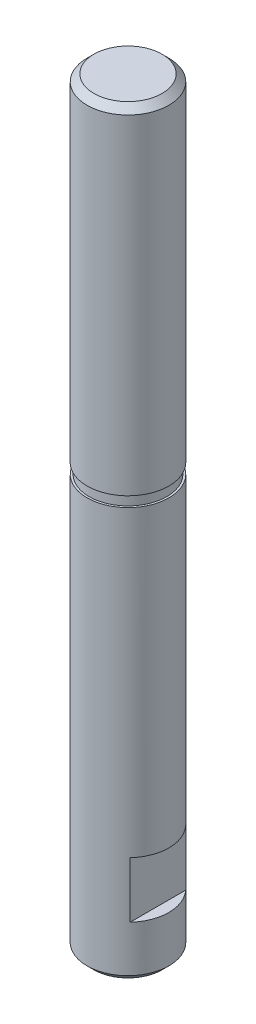
from build123d import *

# Parameters (mm, degrees)
SKETCH1_R           = 3
BOSS_EXTRUDE1_DEPTH = 55.7
SKETCH2_W           = 0.8
SKETCH2_H           = 4.1
CUT_EXTRUDE1_DEPTH  = 4
SKETCH3_W           = 0.15
SKETCH3_H           = 0.75
CHAMFER1_SIZE       = 0.5


with BuildPart() as part:
    # Sketch1 → Boss-Extrude1 (new body)
    with BuildSketch(Plane(origin=(0, 0, 0), x_dir=(1, 0, 0), z_dir=(0, 1, 0))):
        Circle(SKETCH1_R)
    extrude(amount=BOSS_EXTRUDE1_DEPTH)

    # Sketch2 → Cut-Extrude1 (cut, symmetric)
    with BuildSketch(Plane.XY):
        with Locations((-2.6, 5.95)):
            Rectangle(SKETCH2_W, SKETCH2_H)
    cut_extrude1 = extrude(amount=CUT_EXTRUDE1_DEPTH, both=True, mode=Mode.SUBTRACT)

    # Mirror1: Cut-Extrude1 across plane
    add(cut_extrude1.mirror(Plane(origin=(0, 0, 0), x_dir=(0, 0, 1), z_dir=(1, 0, 0))), mode=Mode.SUBTRACT)

    # Sketch3 → Cut-Revolve1 (revolve, cut)
    with BuildSketch(Plane.XY):
        with Locations((2.925, 30.625)):
            Rectangle(SKETCH3_W, SKETCH3_H)
    revolve(axis=Axis((0, 55.7, 0), (0, -1, 0)), mode=Mode.SUBTRACT)

    # Chamfer1
    chamfer1_edges = [part.edges().sort_by_distance(p)[0] for p in [
        (-3, 0, 0),
        (-3, 55.7, 0),
    ]]
    chamfer(chamfer1_edges, length=CHAMFER1_SIZE)


solid = part.part
